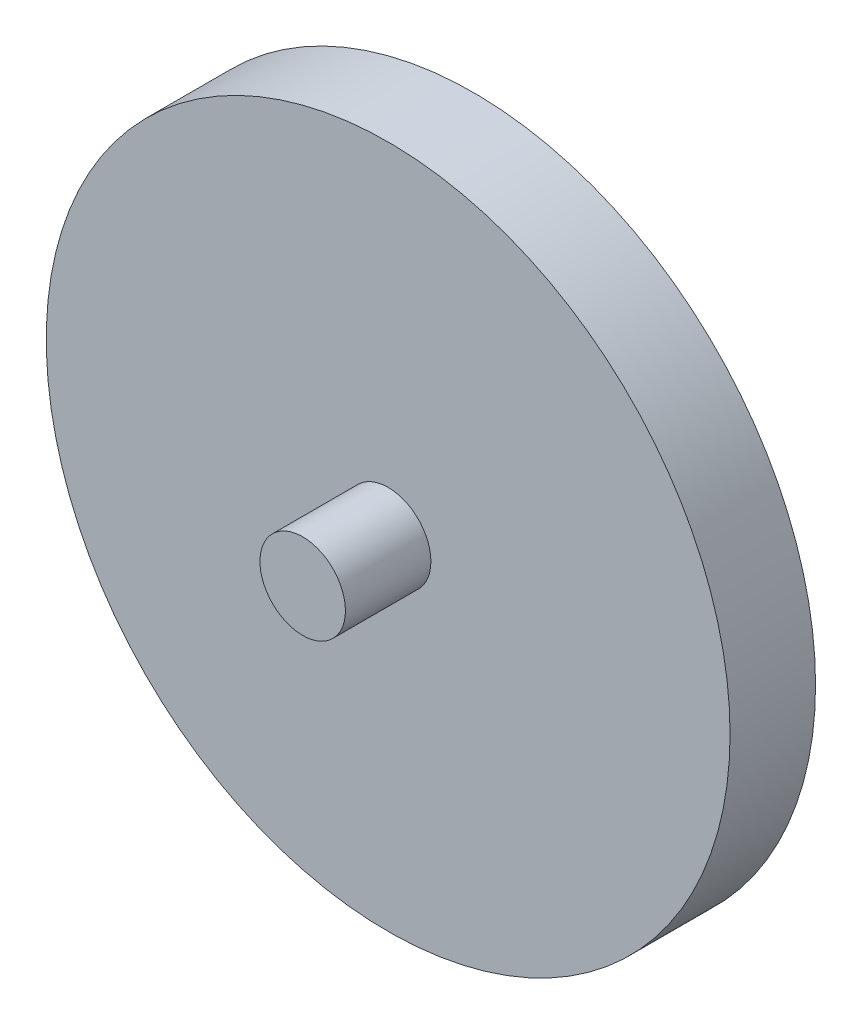
from build123d import *

# Parameters (mm, degrees)
CROQUIS2_R              = 20
SALIENTE_EXTRUIR2_DEPTH = 5
CROQUIS3_R              = 2.5
SALIENTE_EXTRUIR4_DEPTH = 5


with BuildPart() as part:
    # Croquis2 → Saliente-Extruir2 (new body)
    with BuildSketch(Plane.XY):
        Circle(CROQUIS2_R)
    extrude(amount=SALIENTE_EXTRUIR2_DEPTH)

    # Croquis3 → Saliente-Extruir4 (add)
    with BuildSketch(Plane.XY.offset(5)):
        Circle(CROQUIS3_R)
    extrude(amount=SALIENTE_EXTRUIR4_DEPTH)


solid = part.part
